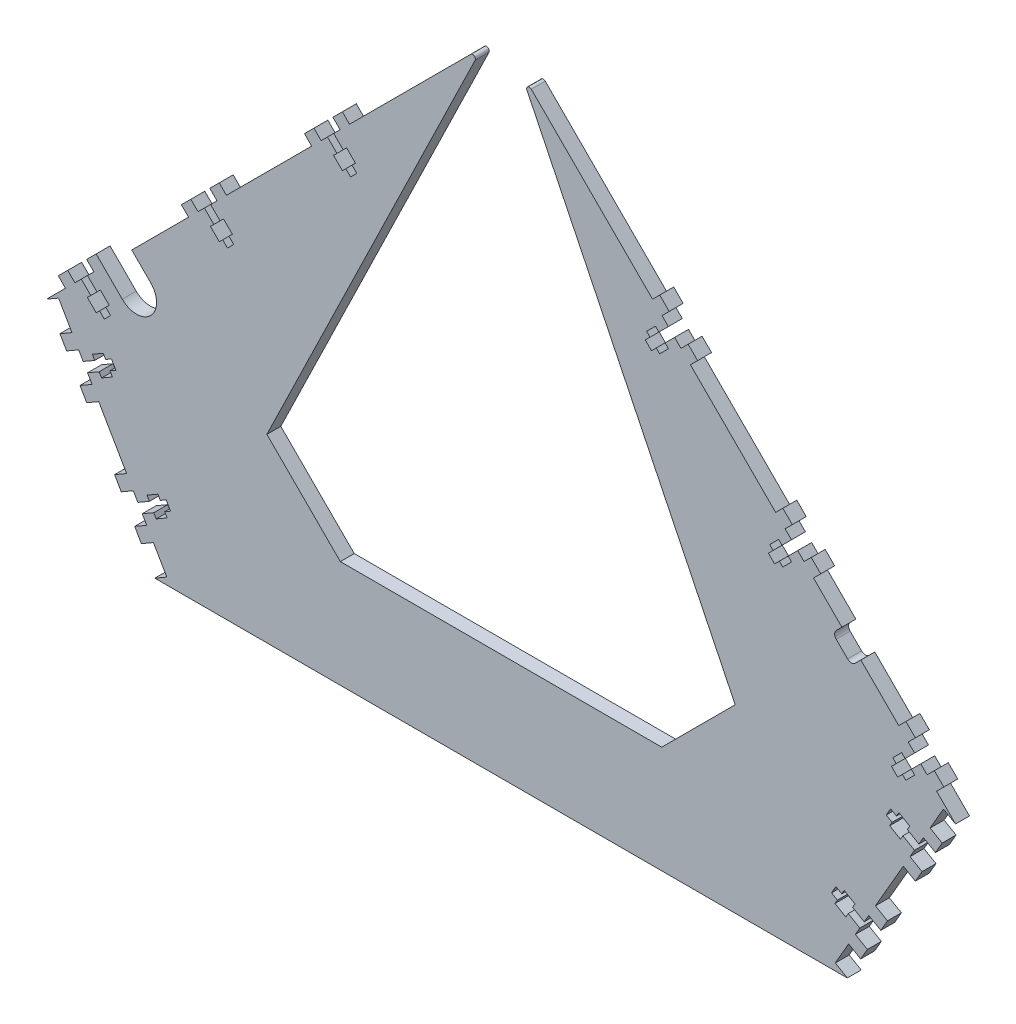
from build123d import *

# Parameters (mm, degrees)
BOSS_EXTRUDE1_DEPTH = 6.604
MOVE_FACE2_BY       = 0.00254
CUT_EXTRUDE1_DEPTH  = 374.058010856
CUT_EXTRUDE2_DEPTH  = 366.767039298
CUT_EXTRUDE3_DEPTH  = 366.767039298
BOSS_EXTRUDE2_DEPTH = 6.604
CUT_EXTRUDE6_DEPTH  = 366.767039298
FILLET1_R           = 1.27
MOVE_FACE3_BY       = 1.778
MOVE_FACE3_2_BY     = 1.778
MOVE_FACE3_3_BY     = 1.778
MOVE_FACE3_4_BY     = 1.778
MOVE_FACE3_5_BY     = 1.778
MOVE_FACE3_6_BY     = 1.778
MOVE_FACE3_7_BY     = 1.778
MOVE_FACE3_8_BY     = 1.778
CUT_EXTRUDE5_DEPTH  = 362.759104609


with BuildPart() as part:
    # Sketch1 → Boss-Extrude1 (new body)
    with BuildSketch(Plane.XY):
        Polygon((0, 304.426146906), (215.526146906, 88.9), (164.199707975, 0), (0, 0), (-164.199707975, 0), (-215.526146906, 88.9), align=None)
    extrude(amount=BOSS_EXTRUDE1_DEPTH)

    # Move Face2: a face moved outward by 0.00254
    extrude(part.faces().sort_by_distance((107.763073453, 196.663073453, 3.302))[0], amount=MOVE_FACE2_BY, dir=(0.707106781, 0.707106781, 0))

    # Sketch2 → Cut-Extrude1 (cut, through all)
    with BuildSketch(Plane.XY.offset(6.604)):
        Polygon((0, 50.8), (76.2, 50.8), (111.033332778, 85.633332778), (8.981570922, 295.448168086), (0.001796051, 304.427942957), (-8.980256121, 295.445890785), (-111.033332778, 85.633332778), (-76.2, 50.8), align=None)
    extrude(amount=-CUT_EXTRUDE1_DEPTH, mode=Mode.SUBTRACT)

    # Sketch3 → Cut-Extrude2 (cut, through all)
    with BuildSketch(Plane.XY.offset(6.604)):
        Polygon((-209.806915139, 92.202), (-215.526146906, 88.9), (-164.199707975, 0), (-158.480476208, 3.302), align=None)
        Polygon((158.480476208, 3.302), (209.806915139, 92.202), (215.526146906, 88.9), (164.199707975, 0), align=None)
    extrude(amount=-CUT_EXTRUDE2_DEPTH, mode=Mode.SUBTRACT)

    # Sketch6 → Cut-Extrude3 (cut, through all)
    with BuildSketch(Plane.XY.offset(6.604)):
        Polygon((-133.231079812, 162.214810972), (-137.721207873, 166.704939033), (-140.66673188, 163.759415025), (-136.17660382, 159.269286965), (-137.793049922, 157.652840863), (-133.590290057, 153.450080998), (-131.973843955, 155.0665271), (-129.710819413, 152.803502558), (-126.765295405, 155.749026565), (-129.028319948, 158.012051108), (-127.411873846, 159.62849721), (-131.61463371, 163.831257074), align=None)
        Polygon((-74.859415025, 220.586475759), (-79.349543086, 225.07660382), (-82.295067093, 222.131079812), (-77.804939033, 217.640951752), (-79.421385135, 216.02450565), (-75.21862527, 211.821745785), (-73.602179168, 213.438191887), (-71.339154626, 211.175167344), (-68.393630618, 214.120691352), (-70.656655161, 216.383715895), (-69.040209059, 218.000161996), (-73.242968923, 222.202921861), align=None)
        Polygon((-191.602744599, 103.843146185), (-196.09287266, 108.333274246), (-199.038396667, 105.387750238), (-194.548268607, 100.897622178), (-196.164714709, 99.281176076), (-191.961954844, 95.078416211), (-190.345508742, 96.694862313), (-188.0824842, 94.431837771), (-185.136960192, 97.377361778), (-187.399984734, 99.640386321), (-185.783538633, 101.256832423), (-189.986298497, 105.459592287), align=None)
        Polygon((-192.649053825, 75.183712455), (-198.148315139, 72.008712455), (-196.065515139, 68.401197033), (-190.566253825, 71.576197033), (-189.423253825, 69.59646296), (-184.275945235, 72.56826296), (-185.418945235, 74.547997033), (-182.647317533, 76.148197033), (-184.730117533, 79.755712455), (-187.501745235, 78.155512455), (-188.644745235, 80.135246528), (-193.792053825, 77.163446528), align=None)
        Polygon((-166.722614894, 30.277802967), (-172.221876208, 27.102802967), (-170.139076208, 23.495287545), (-164.639814894, 26.670287545), (-163.496814894, 24.690553472), (-158.349506304, 27.662353472), (-159.492506304, 29.642087545), (-156.720878602, 31.242287545), (-158.803678602, 34.849802967), (-161.575306304, 33.249602967), (-162.718306304, 35.22933704), (-167.865614894, 32.25753704), align=None)
        Polygon((158.349506304, 27.662353472), (163.496814894, 24.690553472), (164.639814894, 26.670287545), (170.139076208, 23.495287545), (172.221876208, 27.102802967), (166.722614894, 30.277802967), (167.865614894, 32.25753704), (162.718306304, 35.22933704), (161.575306304, 33.249602967), (158.803678602, 34.849802967), (156.720878602, 31.242287545), (159.492506304, 29.642087545), align=None)
        Polygon((198.148315139, 72.008712455), (192.649053825, 75.183712455), (193.792053825, 77.163446528), (188.644745235, 80.135246528), (187.501745235, 78.155512455), (184.730117533, 79.755712455), (182.647317533, 76.148197033), (185.418945235, 74.547997033), (184.275945235, 72.56826296), (189.423253825, 69.59646296), (190.566253825, 71.576197033), (196.065515139, 68.401197033), align=None)
        Polygon((187.401299535, 99.642663622), (185.138274993, 97.37963908), (188.083799, 94.434115072), (190.346823543, 96.697139615), (191.963269645, 95.080693513), (196.166029509, 99.283453378), (194.549583408, 100.899899479), (199.039711468, 105.39002754), (196.09418746, 108.335551548), (191.6040594, 103.845423487), (189.987613298, 105.461869589), (185.784853433, 101.259109724), align=None)
        Polygon((137.722522673, 166.707216335), (133.232394613, 162.217088274), (131.615948511, 163.833534376), (127.413188646, 159.630774511), (129.029634748, 158.014328409), (126.766610206, 155.751303867), (129.712134213, 152.805779859), (131.975158756, 155.068804402), (133.591604858, 153.4523583), (137.794364722, 157.655118165), (136.177918621, 159.271564266), (140.668046681, 163.761692327), align=None)
        Polygon((68.394945419, 214.122968654), (71.340469427, 211.177444646), (73.603493969, 213.440469189), (75.219940071, 211.824023087), (79.422699935, 216.026782952), (77.806253834, 217.643229053), (82.296381894, 222.133357114), (79.350857887, 225.078881122), (74.860729826, 220.588753061), (73.244283724, 222.205199163), (69.04152386, 218.002439298), (70.657969961, 216.385993196), align=None)
    extrude(amount=-CUT_EXTRUDE3_DEPTH, mode=Mode.SUBTRACT)

    # Sketch7 → Boss-Extrude2 (add)
    with BuildSketch(Plane.XY.offset(6.604)):
        Polygon((-133.626211082, 177.624930476), (-130.213713756, 174.21243315), (-134.703841816, 169.72230509), (-138.116339142, 173.134802416), align=None)
        Polygon((-143.684097937, 160.742048969), (-147.096595263, 164.154546295), (-151.586723324, 159.664418234), (-148.174225998, 156.251920908), align=None)
        Polygon((-75.254546295, 235.996595263), (-71.842048969, 232.584097937), (-76.332177029, 228.093969877), (-79.744674355, 231.506467203), align=None)
        Polygon((-85.31243315, 219.113713756), (-88.724930476, 222.526211082), (-93.215058537, 218.036083021), (-89.802561211, 214.623585695), align=None)
        Polygon((-191.997875868, 119.253265689), (-188.585378542, 115.840768363), (-193.075506603, 111.350640303), (-196.488003929, 114.763137629), align=None)
        Polygon((-202.055762724, 102.370384182), (-205.46826005, 105.782881508), (-209.958388111, 101.292753447), (-206.545890785, 97.880256121), align=None)
        Polygon((-207.636353738, 78.790477372), (-203.456915139, 81.203477372), (-200.281915139, 75.704216058), (-204.461353738, 73.291216058), align=None)
        Polygon((-193.931915139, 64.70569343), (-198.111353738, 62.29269343), (-194.936353738, 56.793432116), (-190.756915139, 59.206432116), align=None)
        Polygon((-178.534914807, 28.38530657), (-181.709914807, 33.884567884), (-177.530476208, 36.297567884), (-174.355476208, 30.79830657), align=None)
        Polygon((-172.184914807, 17.386783942), (-169.009914807, 11.887522628), (-164.830476208, 14.300522628), (-168.005476208, 19.799783942), align=None)
        Polygon((169.009914807, 11.887522628), (164.830476208, 14.300522628), (168.005476208, 19.799783942), (172.184914807, 17.386783942), align=None)
        Polygon((181.709914807, 33.884567884), (177.530476208, 36.297567884), (174.355476208, 30.79830657), (178.534914807, 28.38530657), align=None)
        Polygon((193.931915139, 64.70569343), (198.111353738, 62.29269343), (194.936353738, 56.793432116), (190.756915139, 59.206432116), align=None)
        Polygon((207.636353738, 78.790477372), (203.456915139, 81.203477372), (200.281915139, 75.704216058), (204.461353738, 73.291216058), align=None)
        Polygon((209.959702911, 101.295030749), (206.547205585, 97.882533423), (202.057077525, 102.372661483), (205.469574851, 105.785158809), align=None)
        Polygon((193.076821404, 111.352917604), (196.48931873, 114.76541493), (191.999190669, 119.255542991), (188.586693343, 115.843045665), align=None)
        Polygon((143.685412738, 160.74432627), (147.097910064, 164.156823596), (151.588038124, 159.666695536), (148.175540798, 156.25419821), align=None)
        Polygon((134.705156617, 169.724582391), (138.117653943, 173.137079717), (133.627525882, 177.627207778), (130.215028556, 174.214710452), align=None)
        Polygon((75.255861095, 235.998872565), (71.843363769, 232.586375239), (76.33349183, 228.096247178), (79.745989156, 231.508744504), align=None)
        Polygon((85.313747951, 219.115991057), (88.726245277, 222.528488383), (93.216373337, 218.038360323), (89.803876011, 214.625862997), align=None)
    extrude(amount=-BOSS_EXTRUDE2_DEPTH)

    # Sketch10 → Cut-Extrude6 (cut, through all)
    with BuildSketch(Plane.XY.offset(6.604)):
        with BuildLine():
            Line((161.64592498, 142.783814028), (158.951848144, 140.089737192))
            ThreePointArc((158.951848144, 140.089737192), (158.207899368, 138.293685968), (158.951848144, 136.497634743))
            Line((158.951848144, 136.497634743), (164.340001816, 131.109481071))
            ThreePointArc((164.340001816, 131.109481071), (166.136053041, 130.365532295), (167.932104265, 131.109481071))
            Line((167.932104265, 131.109481071), (170.626181101, 133.803557907))
            Line((170.626181101, 133.803557907), (161.64592498, 142.783814028))
        make_face()
    extrude(amount=-CUT_EXTRUDE6_DEPTH, mode=Mode.SUBTRACT)

    # Fillet1
    fillet1_edges = [part.edges().sort_by_distance(p)[0] for p in [
        (-8.980256121, 295.445890785, 3.302),
        (8.981570922, 295.448168086, 3.302),
    ]]
    fillet(fillet1_edges, radius=FILLET1_R)

    # Move Face3: a face moved outward by 1.778
    extrude(part.faces().sort_by_distance((206.048853738, 76.040846715, 3.302))[0], amount=MOVE_FACE3_BY, dir=(0.866025404, -0.5, 0))

    # Move Face3 2: a face moved outward by 1.778
    extrude(part.faces().sort_by_distance((196.523853738, 59.543062773, 3.302))[0], amount=MOVE_FACE3_2_BY, dir=(0.866025404, -0.5, 0))

    # Move Face3 3: a face moved outward by 1.778
    extrude(part.faces().sort_by_distance((180.122414807, 31.134937227, 3.302))[0], amount=MOVE_FACE3_3_BY, dir=(0.866025404, -0.5, 0))

    # Move Face3 4: a face moved outward by 1.778
    extrude(part.faces().sort_by_distance((170.597414807, 14.637153285, 3.302))[0], amount=MOVE_FACE3_4_BY, dir=(0.866025404, -0.5, 0))

    # Move Face3 5: a face moved outward by 1.778
    extrude(part.faces().sort_by_distance((-170.597414807, 14.637153285, 3.302))[0], amount=MOVE_FACE3_5_BY, dir=(-0.866025404, -0.5, 0))

    # Move Face3 6: a face moved outward by 1.778
    extrude(part.faces().sort_by_distance((-180.122414807, 31.134937227, 3.302))[0], amount=MOVE_FACE3_6_BY, dir=(-0.866025404, -0.5, 0))

    # Move Face3 7: a face moved outward by 1.778
    extrude(part.faces().sort_by_distance((-196.523853738, 59.543062773, 3.302))[0], amount=MOVE_FACE3_7_BY, dir=(-0.866025404, -0.5, 0))

    # Move Face3 8: a face moved outward by 1.778
    extrude(part.faces().sort_by_distance((-206.048853738, 76.040846715, 3.302))[0], amount=MOVE_FACE3_8_BY, dir=(-0.866025404, -0.5, 0))

    # Sketch8 → Cut-Extrude5 (cut, through all)
    with BuildSketch(Plane.XY.offset(6.604)):
        with BuildLine():
            Line((-188.585378542, 115.840768363), (-179.605122421, 106.860512242))
            ThreePointArc((-179.605122421, 106.860512242), (-166.13473824, 106.860512242), (-166.13473824, 120.330896424))
            Line((-166.13473824, 120.330896424), (-175.114994361, 129.311152545))
            Line((-175.114994361, 129.311152545), (-188.585378542, 115.840768363))
        make_face()
    extrude(amount=-CUT_EXTRUDE5_DEPTH, mode=Mode.SUBTRACT)


solid = part.part
